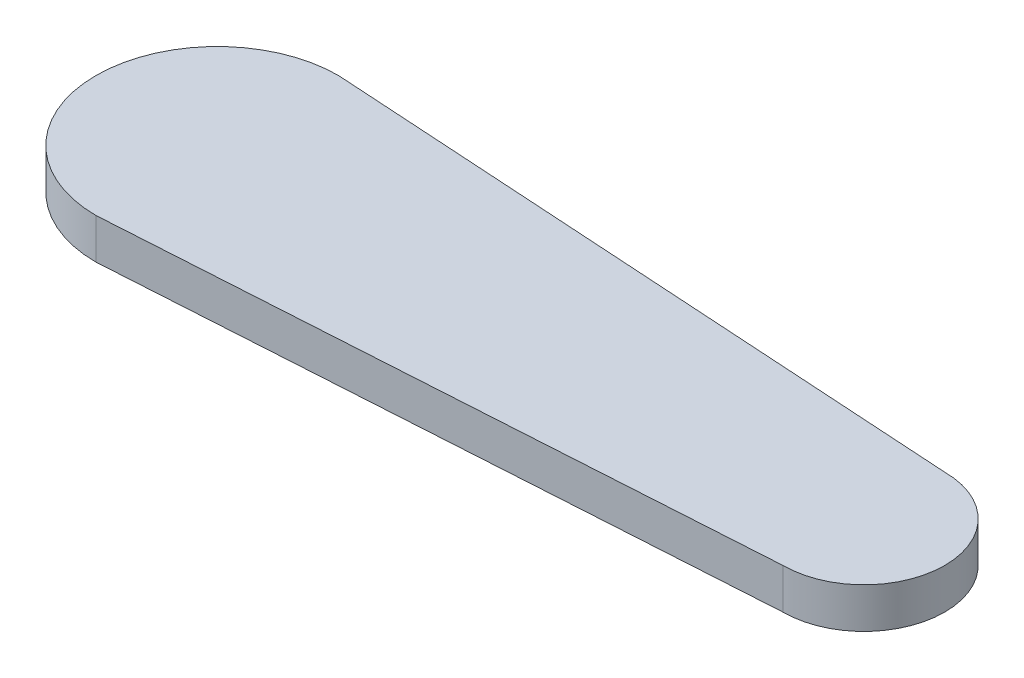
from build123d import *

# Parameters (mm, degrees)
BOSS_EXTRUDE1_DEPTH = 5
CUT_EXTRUDE1_DEPTH  = 1.5


with BuildPart() as part:
    # Sketch1 → Boss-Extrude1 (new body)
    with BuildSketch(Plane(origin=(0, 0, 0), x_dir=(1, 0, 0), z_dir=(0, 1, 0))):
        with BuildLine():
            Line((0, 15), (80, 10))
            ThreePointArc((80, 10), (90, 0), (80, -10))
            Line((80, -10), (0, -15))
            ThreePointArc((0, -15), (-15, 0), (0, 15))
        make_face()
    extrude(amount=BOSS_EXTRUDE1_DEPTH)

    # Sketch1_3 → Cut-Extrude1 (cut)
    with BuildSketch(Plane(origin=(0, 0, 0), x_dir=(1, 0, 0), z_dir=(0, 1, 0))):
        with BuildLine():
            Line((3.3, 7.559743015), (3.3, 4.259743015))
            Line((3.3, 4.259743015), (-11.694677741, 2.297056223))
            ThreePointArc((-11.694677741, 2.297056223), (-13, 0.809743015), (-11.694677741, -0.677570192))
            Line((-11.694677741, -0.677570192), (3.3, -2.640256985))
            Line((3.3, -2.640256985), (3.3, -5.940256985))
            ThreePointArc((3.3, -5.940256985), (5.2, -7.840256985), (7.1, -5.940256985))
            Line((7.1, -5.940256985), (7.1, -2.090256985))
            Line((7.1, -2.090256985), (20.062072923, -0.681475402))
            ThreePointArc((20.062072923, -0.681475402), (21.4, 0.809743015), (20.062072923, 2.300961432))
            Line((20.062072923, 2.300961432), (7.1, 3.709743015))
            Line((7.1, 3.709743015), (7.1, 7.559743015))
            ThreePointArc((7.1, 7.559743015), (5.2, 9.459743015), (3.3, 7.559743015))
        make_face()
    extrude(amount=CUT_EXTRUDE1_DEPTH, mode=Mode.SUBTRACT)


solid = part.part
